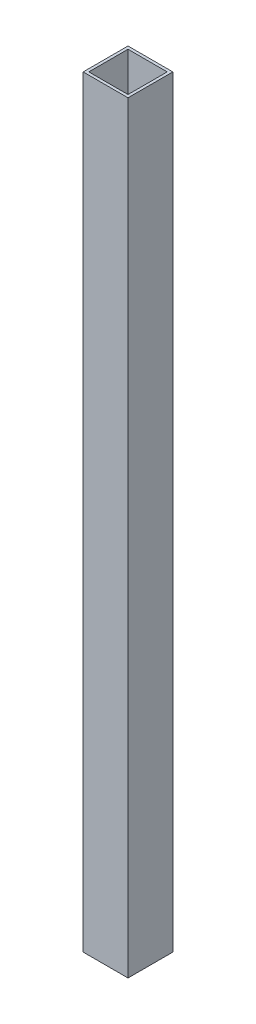
from build123d import *

# Parameters (mm, degrees)
SKETCH1_W           = 25.4
SKETCH1_H           = 25.4
SKETCH1_W_2         = 22.225
SKETCH1_H_2         = 22.225
BOSS_EXTRUDE1_DEPTH = 431.8


with BuildPart() as part:
    # Sketch1 → Boss-Extrude1 (new body)
    with BuildSketch(Plane(origin=(0, 0, 0), x_dir=(1, 0, 0), z_dir=(0, 1, 0))):
        Rectangle(SKETCH1_W, SKETCH1_H)
        Rectangle(SKETCH1_W_2, SKETCH1_H_2, mode=Mode.SUBTRACT)
    extrude(amount=BOSS_EXTRUDE1_DEPTH)


solid = part.part
